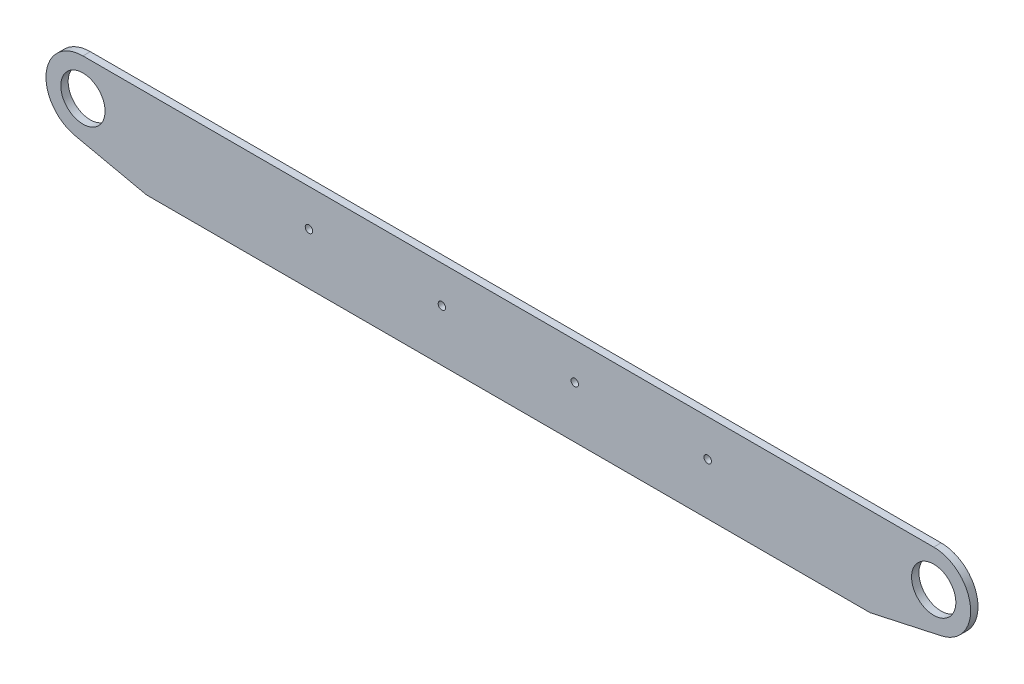
from build123d import *

# Parameters (mm, degrees)
SKETCH1_W                   = 622.3
SKETCH1_H                   = 76.2
BOSS_EXTRUDE1_DEPTH         = 6.35
F_1_4_0_25_DIAMETER_HOLE1_D = 6.35
LPATTERN1_COUNT             = 4
LPATTERN1_PITCH             = 114.3
SKETCH4_R                   = 19.05
BOSS_EXTRUDE3_DEPTH         = 6.35


with BuildPart() as part:
    # Sketch1 → Boss-Extrude1 (new body)
    with BuildSketch(Plane.XY.offset(457.2)):
        with Locations((0, 571.5)):
            Rectangle(SKETCH1_W, SKETCH1_H)
    extrude(amount=BOSS_EXTRUDE1_DEPTH)

    # 1/4 (0.25) Diameter Hole1 (through all)
    with Locations(Plane.XY.offset(463.55)):
        with Locations((171.45, 577.85)):
            f_1_4_0_25_diameter_hole1 = Hole(F_1_4_0_25_DIAMETER_HOLE1_D / 2)

    # LPattern1: 1/4 (0.25) Diameter Hole1 ×4
    with Locations(*[(-i * LPATTERN1_PITCH, 0, 0) for i in range(1, LPATTERN1_COUNT)]):
        add(f_1_4_0_25_diameter_hole1, mode=Mode.SUBTRACT)

    # Sketch4 → Boss-Extrude3 (add)
    with BuildSketch(Plane.XY.offset(463.55)):
        with BuildLine():
            Line((311.15, 533.4), (372.587826171, 546.832705994))
            ThreePointArc((372.587826171, 546.832705994), (397.37252749, 581.26052894), (365.806235462, 609.6))
            Line((365.806235462, 609.6), (311.15, 609.6))
            Line((311.15, 609.6), (311.15, 533.4))
        make_face()
        with Locations((365.806235462, 577.85)):
            Circle(SKETCH4_R, mode=Mode.SUBTRACT)
    boss_extrude3 = extrude(amount=-BOSS_EXTRUDE3_DEPTH)

    # Mirror1: Boss-Extrude3 across plane
    add(boss_extrude3.mirror(Plane(origin=(0, 0, 0), x_dir=(0, 0, 1), z_dir=(1, 0, 0))))


solid = part.part
